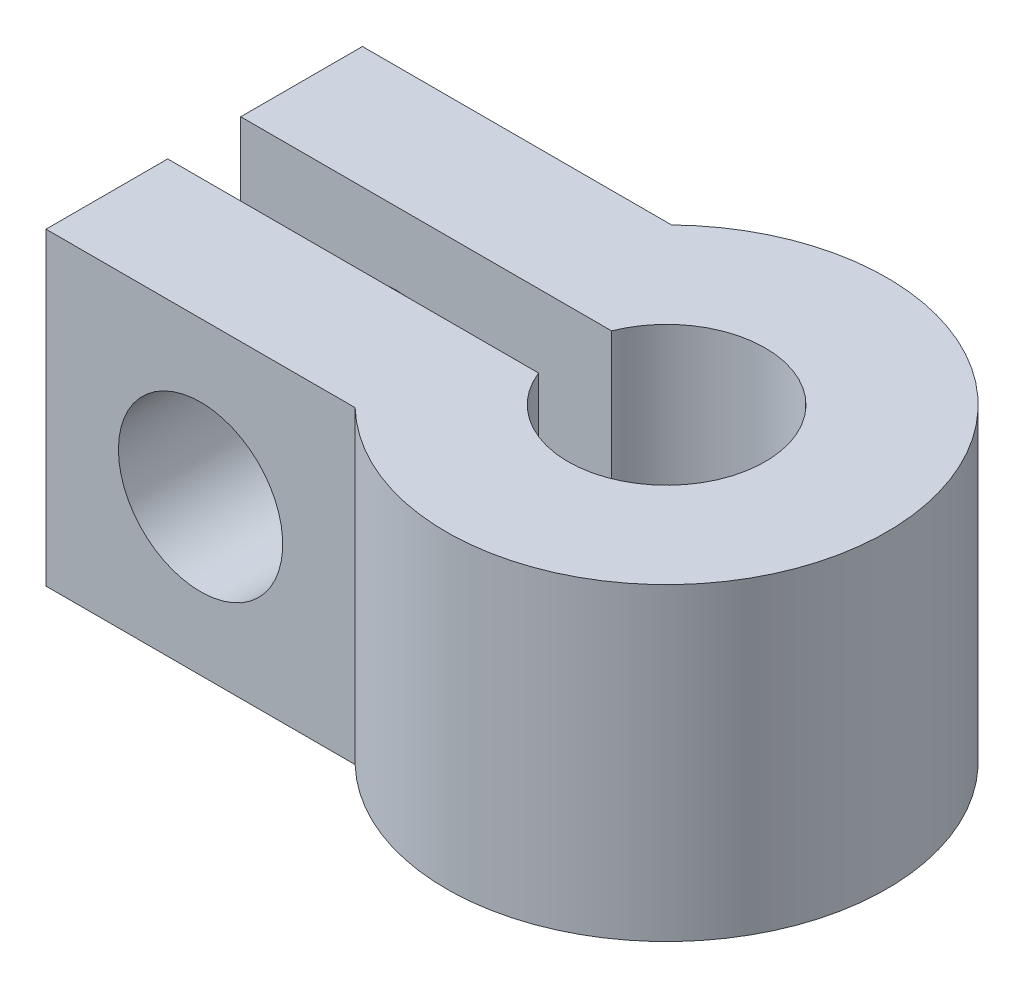
from build123d import *

# Parameters (mm, degrees)
BOSS_EXTRUDE1_DEPTH = 12.7
SKETCH2_R           = 3.375
CUT_EXTRUDE1_DEPTH  = 16.55


with BuildPart() as part:
    # Sketch1 → Boss-Extrude1 (new body)
    with BuildSketch(Plane(origin=(0, 0, 0), x_dir=(1, 0, 0), z_dir=(0, 1, 0))):
        with BuildLine():
            Line((-18.997023106, 1.5), (-3.761980861, 1.5))
            ThreePointArc((-3.761980861, 1.5), (0.763700698, 3.977343491), (4.05, 0))
            ThreePointArc((4.05, 0), (0.763700698, -3.977343491), (-3.761980861, -1.5))
            Line((-3.761980861, -1.5), (-18.997023106, -1.5))
            Line((-18.997023106, -1.5), (-18.997023106, -6.5))
            Line((-18.997023106, -6.5), (-6.297023106, -6.5))
            ThreePointArc((-6.297023106, -6.5), (9.05, 0), (-6.297023106, 6.5))
            Line((-6.297023106, 6.5), (-18.997023106, 6.5))
            Line((-18.997023106, 6.5), (-18.997023106, 1.5))
        make_face()
    extrude(amount=BOSS_EXTRUDE1_DEPTH)

    # Sketch2 → Cut-Extrude1 (cut, through all)
    with BuildSketch(Plane(origin=(0, 0, -6.5), x_dir=(-1, 0, 0), z_dir=(0, 0, -1))):
        with Locations((12.647023106, 6.35)):
            Circle(SKETCH2_R)
    extrude(amount=-CUT_EXTRUDE1_DEPTH, mode=Mode.SUBTRACT)


solid = part.part
